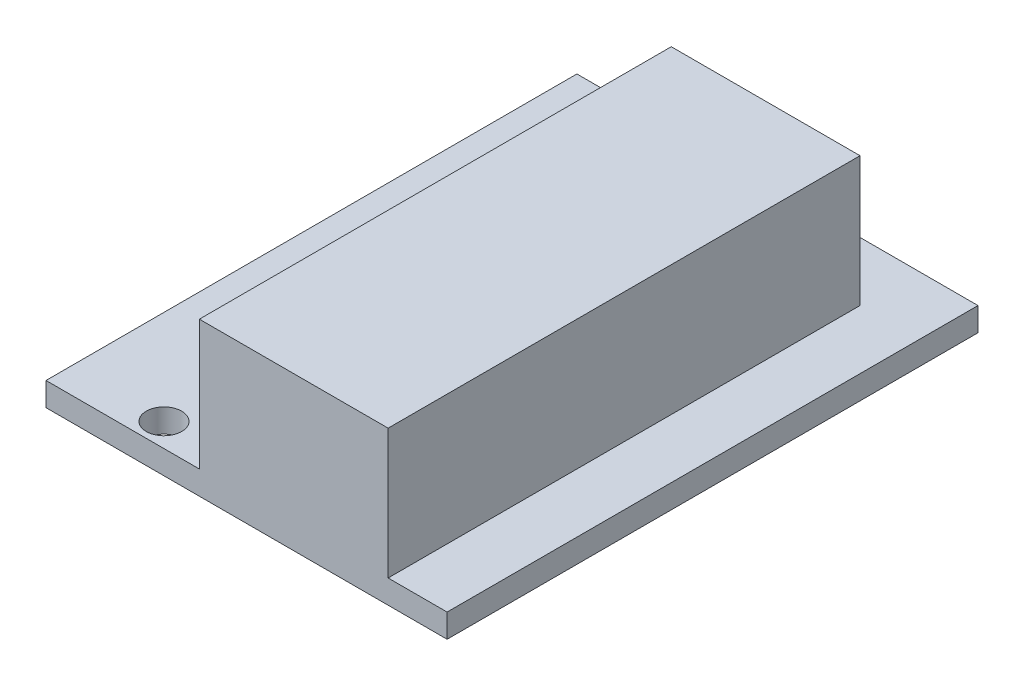
from build123d import *

# Parameters (mm, degrees)
SKETCH1_W              = 34
SKETCH1_H              = 112
SKETCH1_R              = 1.5
BOARD_DEPTH            = 2
SKETCH2_W              = 16
SKETCH2_H              = 40
SKETCH2_W_2            = 6
SKETCH2_H_2            = 10
F_7SEG_DEPTH           = 11
SKETCH3_W              = 10
SKETCH3_H              = 20
SKETCH3_H_2            = 10
IC_DEPTH               = 8
SKETCH5_W              = 9
SKETCH5_H              = 17
BIENTROA_DEPTH         = 23
SKETCH6_R              = 3.4
BIENTROB_DEPTH         = 15
SKETCH7_W              = 10
SKETCH7_H              = 5
IRF540_DEPTH           = 26
SKETCH8_W              = 17
SKETCH8_H              = 10
DOMINO_DEPTH           = 10
SKETCH9_W              = 22
SKETCH9_H              = 30
EXTRUDE_7805_DEPTH     = 30
SPLIT2_SURFACE_1_BACK  = 127.76
SPLIT2_SURFACE_1_DEPTH = 255.52
SPLIT2_SURFACE_2_BACK  = 127.76
SPLIT2_SURFACE_2_DEPTH = 255.52


with BuildPart() as part:
    # Sketch1 → Board (new body)
    with BuildSketch(Plane(origin=(0, 0, 0), x_dir=(1, 0, 0), z_dir=(0, 1, 0))):
        Rectangle(SKETCH1_W, SKETCH1_H)
        with Locations(Location((13.6, -52.6, 0), (0, 0, 270))):
            Circle(SKETCH1_R, mode=Mode.SUBTRACT)
        with Locations(Location((-9, 49, 0), (0, 0, 270))):
            Circle(SKETCH1_R, mode=Mode.SUBTRACT)
        with Locations(Location((-9, 13, 0), (0, 0, 270))):
            Circle(SKETCH1_R, mode=Mode.SUBTRACT)
    extrude(amount=BOARD_DEPTH)

    # Sketch2 → 7SEG (add)
    with BuildSketch(Plane(origin=(0, 2, 0), x_dir=(1, 0, 0), z_dir=(0, 1, 0))):
        with Locations((4, 31)):
            Rectangle(SKETCH2_W, SKETCH2_H)
        with Locations((8, 5)):
            Rectangle(SKETCH2_W_2, SKETCH2_H_2)
    extrude(amount=F_7SEG_DEPTH)

    # Sketch3 → IC (add)
    with BuildSketch(Plane(origin=(0, 2, 0), x_dir=(1, 0, 0), z_dir=(0, 1, 0))):
        with Locations((-2, 26)):
            Rectangle(SKETCH3_W, SKETCH3_H)
        with Locations((4, 5)):
            Rectangle(SKETCH3_W, SKETCH3_H_2)
        with Locations((4, -17)):
            Rectangle(SKETCH3_W, SKETCH3_H_2)
    extrude(amount=IC_DEPTH)

    # Sketch5 → BienTroA (add)
    with BuildSketch(Plane(origin=(0, 2, 0), x_dir=(1, 0, 0), z_dir=(0, 1, 0))):
        with Locations((6.5, -14.5)):
            Rectangle(SKETCH5_W, SKETCH5_H)
    extrude(amount=BIENTROA_DEPTH)

    # Sketch6 → BienTroB (add)
    with BuildSketch(Plane(origin=(11, 0, 0), x_dir=(0, 0, -1), z_dir=(1, 0, 0))):
        with Locations(Location((-14.5, 16.6, 0), (0, 0, 180))):
            Circle(SKETCH6_R)
    extrude(amount=BIENTROB_DEPTH)

    # Sketch7 → IRF540 (add)
    with BuildSketch(Plane(origin=(0, 2, 0), x_dir=(1, 0, 0), z_dir=(0, 1, 0))):
        with Locations((5, -47.5)):
            Rectangle(SKETCH7_W, SKETCH7_H)
    extrude(amount=IRF540_DEPTH)

    # Sketch8 → Domino (add)
    with BuildSketch(Plane(origin=(0, 2, 0), x_dir=(1, 0, 0), z_dir=(0, 1, 0))):
        with Locations((-2.5, -50)):
            Rectangle(SKETCH8_W, SKETCH8_H)
    extrude(amount=DOMINO_DEPTH)

    # Sketch9 → 7805 (add)
    with BuildSketch(Plane(origin=(0, 2, 0), x_dir=(1, 0, 0), z_dir=(0, 1, 0))):
        with Locations((-13, -26)):
            Rectangle(SKETCH9_W, SKETCH9_H)
    extrude(amount=EXTRUDE_7805_DEPTH)


with BuildPart() as body_2:
    # Split2: the piece behind the surface
    add(part.part)
    # Split2 surface: a surface, the sketch's curves swept straight by 255.52 mm
    with BuildLine(Plane(origin=(0, 2, 0), x_dir=(1, 0, 0), z_dir=(0, 1, 0)).offset(-SPLIT2_SURFACE_1_BACK), mode=Mode.PRIVATE) as split2_surface_1_path:
        Line((17, 11), (-17, 11))
    split2_surface_1 = Shell.extrude(split2_surface_1_path.wire(), (0 * SPLIT2_SURFACE_1_DEPTH, 1 * SPLIT2_SURFACE_1_DEPTH, 0 * SPLIT2_SURFACE_1_DEPTH))
    split(bisect_by=split2_surface_1, keep=Keep.BOTTOM)


with BuildPart() as part_1:
    add(part.part)

    # Split2: split by a surface, the side it looks to stays
    # Split2 surface: a surface, the sketch's curves swept straight by 255.52 mm
    with BuildLine(Plane(origin=(0, 2, 0), x_dir=(1, 0, 0), z_dir=(0, 1, 0)).offset(-SPLIT2_SURFACE_2_BACK), mode=Mode.PRIVATE) as split2_surface_2_path:
        Line((17, 11), (-17, 11))
    split2_surface_2 = Shell.extrude(split2_surface_2_path.wire(), (0 * SPLIT2_SURFACE_2_DEPTH, 1 * SPLIT2_SURFACE_2_DEPTH, 0 * SPLIT2_SURFACE_2_DEPTH))
    split(bisect_by=split2_surface_2, keep=Keep.TOP)


solid = body_2.part
